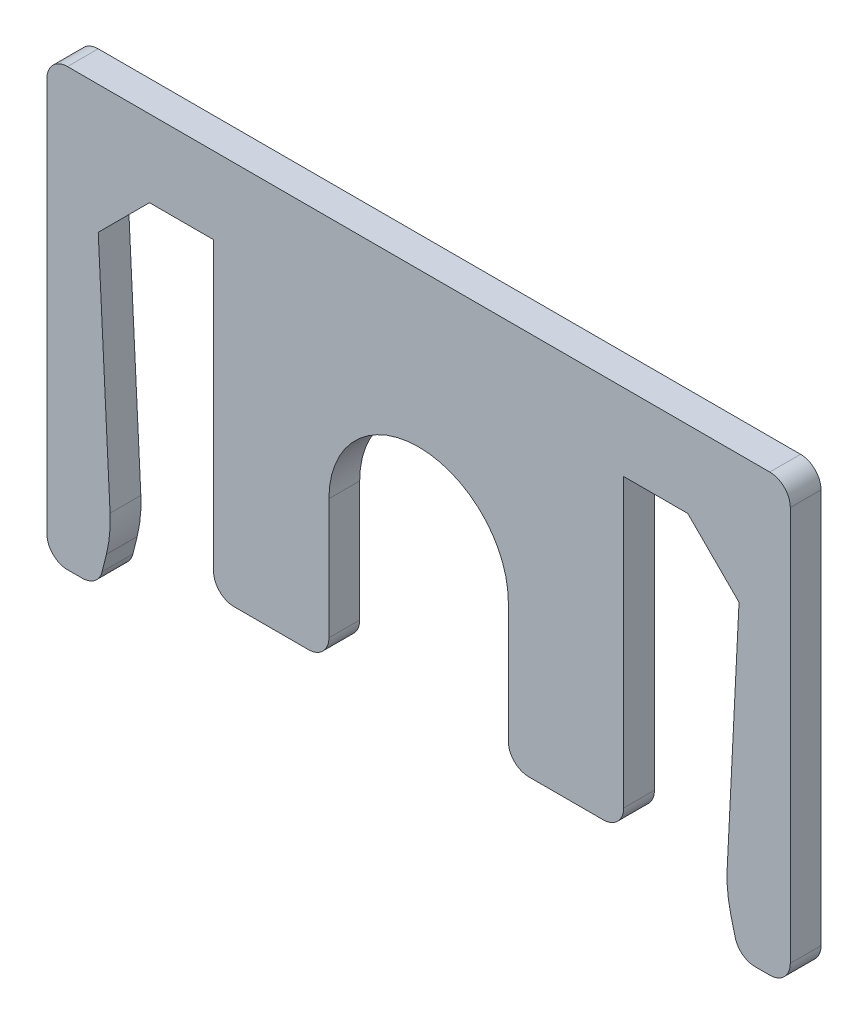
from build123d import *

# Parameters (mm, degrees)
BOSS_EXTRUDE1_DEPTH = 1.2
FILLET1_R           = 5
FILLET2_R           = 0.8


with BuildPart() as part:
    # Sketch1 → Boss-Extrude1 (new body)
    with BuildSketch(Plane.XY):
        with BuildLine():
            Line((-10.5, 0), (-12.5, -2))
            Line((-12.5, -2), (-12, -12))
            Line((-12, -12), (-12.5, -14))
            Line((-12.5, -14), (-14.5, -14))
            Line((-14.5, -14), (-14.5, 3))
            Line((-14.5, 3), (-12.5, 3))
            Line((-12.5, 3), (12.5, 3))
            Line((12.5, 3), (14.5, 3))
            Line((14.5, 3), (14.5, -14))
            Line((14.5, -14), (12.5, -14))
            Line((12.5, -14), (12, -12))
            Line((12, -12), (12.5, -2))
            Line((12.5, -2), (10.5, 0))
            Line((10.5, 0), (8, 0))
            Line((8, 0), (8, -12))
            Line((8, -12), (3.5, -12))
            Line((3.5, -12), (3.5, -6.5))
            ThreePointArc((3.5, -6.5), (0, -3), (-3.5, -6.5))
            Line((-3.5, -6.5), (-3.5, -12))
            Line((-3.5, -12), (-8, -12))
            Line((-8, -12), (-8, 0))
            Line((-8, 0), (-10.5, 0))
        make_face()
    extrude(amount=BOSS_EXTRUDE1_DEPTH)

    # Fillet1
    fillet1_edges = [part.edges().sort_by_distance(p)[0] for p in [
        (-12, -12, 0.6),
        (12, -12, 0.6),
    ]]
    fillet(fillet1_edges, radius=FILLET1_R)

    # Fillet2
    fillet2_edges = [part.edges().sort_by_distance(p)[0] for p in [
        (-12.5, -14, 0.6),
        (-14.5, -14, 0.6),
        (-14.5, 3, 0.6),
        (14.5, 3, 0.6),
        (14.5, -14, 0.6),
        (12.5, -14, 0.6),
        (8, -12, 0.6),
        (3.5, -12, 0.6),
        (-3.5, -12, 0.6),
        (-8, -12, 0.6),
    ]]
    fillet(fillet2_edges, radius=FILLET2_R)


solid = part.part
